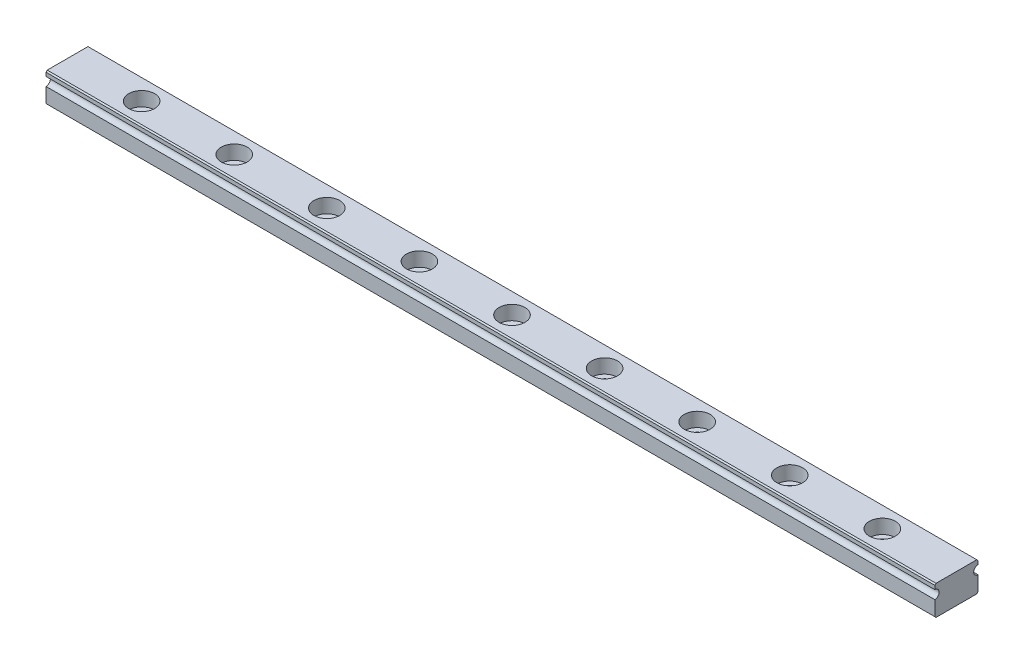
from build123d import *

# Parameters (mm, degrees)
EXTRUDE_1_DEPTH          = 144
SKETCH_2_R               = 2.1
CUT_EXTRUDE_1_DEPTH      = 2.3
SKETCH_3_R               = 1.2
CUT_EXTRUDE_2_DEPTH      = 1
CUT_EXTRUDE_2_DEPTH_BACK = 5.795979797


with BuildPart() as part:
    # 草图1 → 凸台-拉伸1 (new body)
    with BuildSketch(Plane(origin=(0, 0, 0), x_dir=(0, 0, -1), z_dir=(1, 0, 0))):
        with BuildLine():
            Line((3.497989899, 0.202010101), (3.497989899, -2.197989899))
            Line((3.497989899, -2.197989899), (3.3, -2.395979797))
            Line((3.3, -2.395979797), (-3.3, -2.395979797))
            Line((-3.3, -2.395979797), (-3.497989899, -2.197989899))
            Line((-3.497989899, -2.197989899), (-3.497989899, 0.202010101))
            ThreePointArc((-3.497989899, 0.202010101), (-2.797989899, 0.902010101), (-3.497989899, 1.602010101))
            Line((-3.497989899, 1.602010101), (-3.497989899, 2.202010101))
            Line((-3.497989899, 2.202010101), (-3.3, 2.4))
            Line((-3.3, 2.4), (3.3, 2.4))
            Line((3.3, 2.4), (3.497989899, 2.202010101))
            Line((3.497989899, 2.202010101), (3.497989899, 1.602010101))
            ThreePointArc((3.497989899, 1.602010101), (2.797989899, 0.902010101), (3.497989899, 0.202010101))
        make_face()
    extrude(amount=EXTRUDE_1_DEPTH)

    # 草图2 → 切除-拉伸1 (cut)
    with BuildSketch(Plane(origin=(0, 2.4, 0), x_dir=(1, 0, 0), z_dir=(0, 1, 0))):
        with Locations((12, 0)):
            Circle(SKETCH_2_R)
        with Locations((27, 0)):
            Circle(SKETCH_2_R)
        with Locations((42, 0)):
            Circle(SKETCH_2_R)
        with Locations((57, 0)):
            Circle(SKETCH_2_R)
        with Locations((72, 0)):
            Circle(SKETCH_2_R)
        with Locations((87, 0)):
            Circle(SKETCH_2_R)
        with Locations((102, 0)):
            Circle(SKETCH_2_R)
        with Locations((117, 0)):
            Circle(SKETCH_2_R)
        with Locations((132, 0)):
            Circle(SKETCH_2_R)
        with Locations((147, 0)):
            Circle(SKETCH_2_R)
        with Locations((162, 0)):
            Circle(SKETCH_2_R)
        with Locations((177, 0)):
            Circle(SKETCH_2_R)
        with Locations((192, 0)):
            Circle(SKETCH_2_R)
        with Locations((207, 0)):
            Circle(SKETCH_2_R)
        with Locations((222, 0)):
            Circle(SKETCH_2_R)
    extrude(amount=-CUT_EXTRUDE_1_DEPTH, mode=Mode.SUBTRACT)

    # 草图3 → 切除-拉伸2 (cut, two sides)
    with BuildSketch(Plane(origin=(0, 2.4, 0), x_dir=(1, 0, 0), z_dir=(0, 1, 0))) as cut_extrude_2_sk:
        with Locations((12, 0)):
            Circle(SKETCH_3_R)
        with Locations((27, 0)):
            Circle(SKETCH_3_R)
        with Locations((42, 0)):
            Circle(SKETCH_3_R)
        with Locations((57, 0)):
            Circle(SKETCH_3_R)
        with Locations((72, 0)):
            Circle(SKETCH_3_R)
        with Locations((87, 0)):
            Circle(SKETCH_3_R)
        with Locations((102, 0)):
            Circle(SKETCH_3_R)
        with Locations((117, 0)):
            Circle(SKETCH_3_R)
        with Locations((132, 0)):
            Circle(SKETCH_3_R)
        with Locations((147, 0)):
            Circle(SKETCH_3_R)
        with Locations((162, 0)):
            Circle(SKETCH_3_R)
        with Locations((177, 0)):
            Circle(SKETCH_3_R)
        with Locations((192, 0)):
            Circle(SKETCH_3_R)
        with Locations((207, 0)):
            Circle(SKETCH_3_R)
        with Locations((222, 0)):
            Circle(SKETCH_3_R)
    extrude(amount=CUT_EXTRUDE_2_DEPTH, mode=Mode.SUBTRACT)
    extrude(cut_extrude_2_sk.sketch, amount=-CUT_EXTRUDE_2_DEPTH_BACK, mode=Mode.SUBTRACT)


solid = part.part
